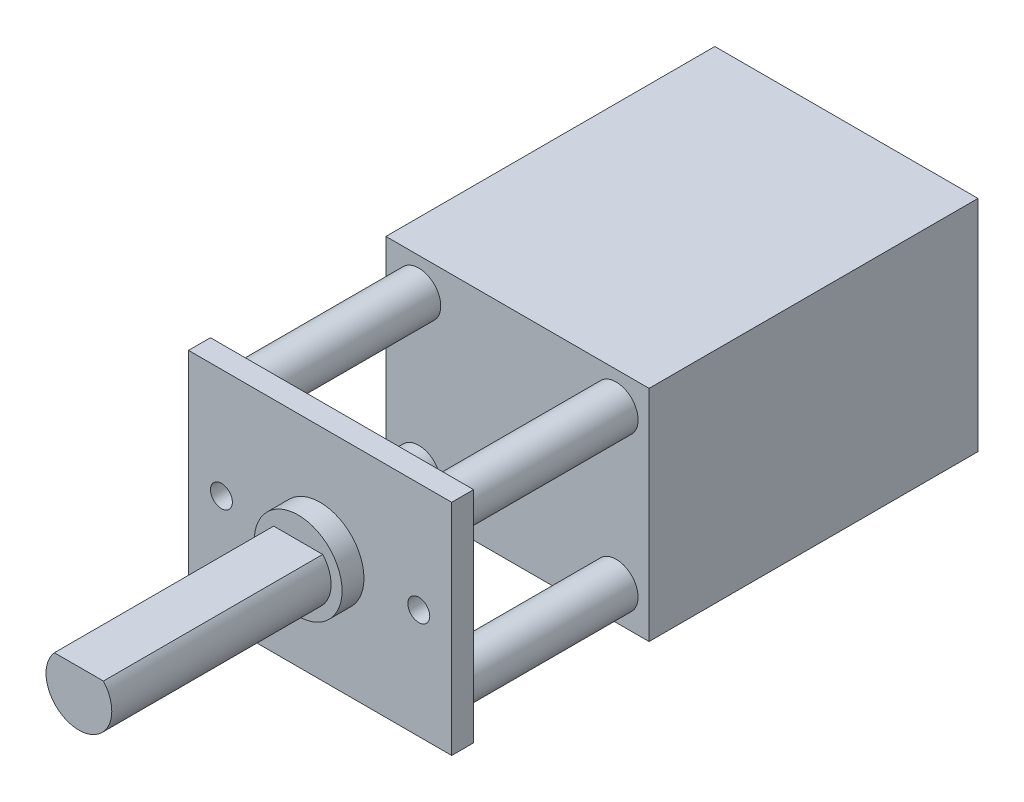
from build123d import *

# Parameters (mm, degrees)
SKETCH_1_W          = 12
SKETCH_1_H          = 10
EXTRUDE_1_DEPTH     = 1
SKETCH_2_R          = 1
EXTRUDE_2_DEPTH     = 8
SKETCH_3_R          = 2
EXTRUDE_3_DEPTH     = 1
EXTRUDE_4_DEPTH     = 10
SKETCH_5_W          = 12
SKETCH_5_H          = 10
EXTRUDE_5_DEPTH     = 15
CUT_EXTRUDE_1_REACH = 14
SKETCH_6_R          = 0.5


with BuildPart() as part:
    # 草图1 → 凸台-拉伸1 (new body)
    with BuildSketch(Plane.XY):
        Rectangle(SKETCH_1_W, SKETCH_1_H)
    extrude(amount=EXTRUDE_1_DEPTH)

    # 草图2 → 凸台-拉伸2 (add)
    with BuildSketch(Plane(origin=(0, 0, 0), x_dir=(-1, 0, 0), z_dir=(0, 0, -1))):
        with Locations((-4.5, 3.5)):
            Circle(SKETCH_2_R)
        with Locations((4.5, 3.5)):
            Circle(SKETCH_2_R)
        with Locations((4.5, -3.5)):
            Circle(SKETCH_2_R)
        with Locations((-4.5, -3.5)):
            Circle(SKETCH_2_R)
    extrude(amount=EXTRUDE_2_DEPTH)

    # 草图3 → 凸台-拉伸3 (add)
    with BuildSketch(Plane.XY.offset(1)):
        Circle(SKETCH_3_R)
    extrude(amount=EXTRUDE_3_DEPTH)

    # 草图4 → 凸台-拉伸4 (add)
    with BuildSketch(Plane.XY.offset(2)):
        with BuildLine():
            Line((-1.118033989, 1), (1.118033989, 1))
            ThreePointArc((1.118033989, 1), (0, -1.5), (-1.118033989, 1))
        make_face()
    extrude(amount=EXTRUDE_4_DEPTH)

    # 草图5 → 凸台-拉伸5 (add)
    with BuildSketch(Plane(origin=(0, 0, -8), x_dir=(-1, 0, 0), z_dir=(0, 0, -1))):
        Rectangle(SKETCH_5_W, SKETCH_5_H)
    extrude(amount=EXTRUDE_5_DEPTH)

    # 草图6 → 切除-拉伸1 (cut, up to next)
    with BuildSketch(Plane(origin=(0, 0, 0), x_dir=(-1, 0, 0), z_dir=(0, 0, -1)), mode=Mode.PRIVATE) as cut_extrude_1_sk1:
        with Locations((-4.5, 0)):
            Circle(SKETCH_6_R)
    cut_extrude_1_tool1 = extrude(cut_extrude_1_sk1.sketch, amount=-CUT_EXTRUDE_1_REACH, mode=Mode.PRIVATE) & part.part
    add(cut_extrude_1_tool1.solids().sort_by_distance((4.5, 0, 0))[0], mode=Mode.SUBTRACT)
    # 草图6 → 切除-拉伸1 (cut, up to next)
    with BuildSketch(Plane(origin=(0, 0, 0), x_dir=(-1, 0, 0), z_dir=(0, 0, -1)), mode=Mode.PRIVATE) as cut_extrude_1_sk2:
        with Locations((4.5, 0)):
            Circle(SKETCH_6_R)
    cut_extrude_1_tool2 = extrude(cut_extrude_1_sk2.sketch, amount=-CUT_EXTRUDE_1_REACH, mode=Mode.PRIVATE) & part.part
    add(cut_extrude_1_tool2.solids().sort_by_distance((-4.5, 0, 0))[0], mode=Mode.SUBTRACT)


solid = part.part
